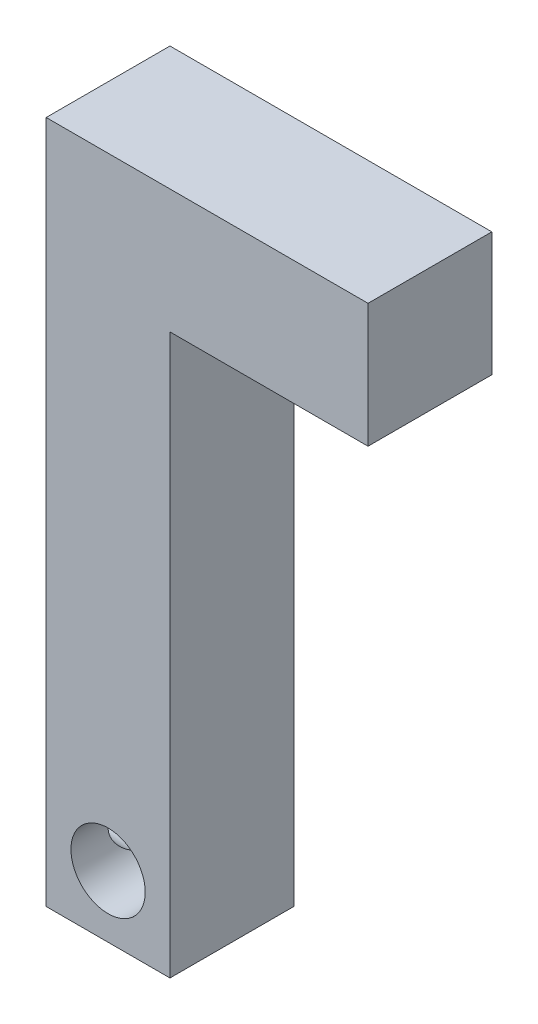
from build123d import *

# Parameters (mm, degrees)
BOSS_EXTRUDE1_DEPTH = 6.35
SKETCH2_R           = 1.905
CUT_EXTRUDE1_DEPTH  = 7.35
CUT_EXTRUDE2_REACH  = 18.51
SKETCH3_R           = 1.27


with BuildPart() as part:
    # Sketch1 → Boss-Extrude1 (new body)
    with BuildSketch(Plane.XY):
        Polygon((0, 0), (0, -35.052), (6.35, -35.052), (6.35, -6.35), (16.51, -6.35), (16.51, 0), align=None)
    extrude(amount=BOSS_EXTRUDE1_DEPTH)

    # Sketch2 → Cut-Extrude1 (cut, through all)
    with BuildSketch(Plane.XY.offset(6.35)):
        with Locations((3.175, -31.877)):
            Circle(SKETCH2_R)
    extrude(amount=-CUT_EXTRUDE1_DEPTH, mode=Mode.SUBTRACT)

    # Sketch3 → Cut-Extrude2 (cut, up to next)
    with BuildSketch(Plane.ZY, mode=Mode.PRIVATE) as cut_extrude2_sk1:
        with Locations((3.175, -31.877)):
            Circle(SKETCH3_R)
    cut_extrude2_tool1 = extrude(cut_extrude2_sk1.sketch, amount=-CUT_EXTRUDE2_REACH, mode=Mode.PRIVATE) & part.part
    add(cut_extrude2_tool1.solids().sort_by_distance((0, -31.877, 3.175))[0], mode=Mode.SUBTRACT)


solid = part.part
